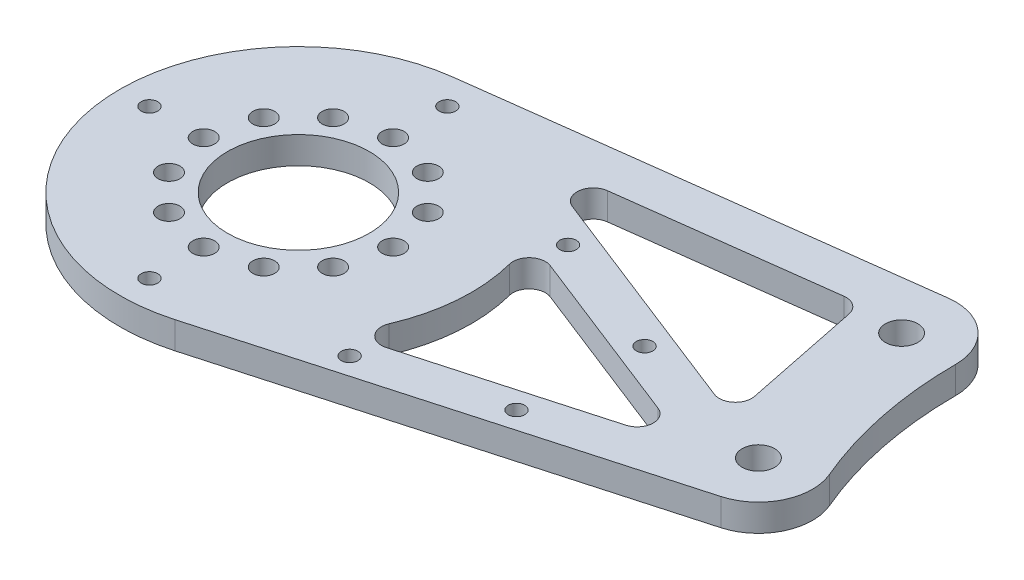
from build123d import *

# Parameters (mm, degrees)
SKETCH_1_R          = 2.025
SKETCH_1_R_2        = 13.1
SKETCH_1_R_3        = 3
EXTRUDE_1_DEPTH     = 5
CUT_EXTRUDE_3_DEPTH = 10
FILLET_2_R          = 3
SKETCH_5_R          = 1.525
CUT_EXTRUDE_4_DEPTH = 20


with BuildPart() as part:
    # 草图1 → 凸台-拉伸1 (new body)
    with BuildSketch(Plane(origin=(0, 0, 0), x_dir=(1, 0, 0), z_dir=(0, 1, 0))):
        with BuildLine():
            Line((76.972140647, 43.13107423), (-4.193547259, 32.732463418))
            ThreePointArc((-4.193547259, 32.732463418), (-32.337515252, -6.579141836), (8.929411765, -31.768940894))
            Line((8.929411765, -31.768940894), (87.705882353, -9.626951786))
            ThreePointArc((87.705882353, -9.626951786), (94.014523475, -4.328783491), (94.205048973, 3.907310252))
            ThreePointArc((94.205048973, 3.907310252), (89.748559809, 18.25955029), (88.242912543, 33.212145922))
            ThreePointArc((88.242912543, 33.212145922), (84.849435117, 40.719066694), (76.972140647, 43.13107423))
        make_face()
        with Locations((0, 17.5)):
            Circle(SKETCH_1_R, mode=Mode.SUBTRACT)
        with Locations((8.75, 15.155444566)):
            Circle(SKETCH_1_R, mode=Mode.SUBTRACT)
        with Locations((-8.75, -15.155444566)):
            Circle(SKETCH_1_R, mode=Mode.SUBTRACT)
        with Locations((0, -17.5)):
            Circle(SKETCH_1_R, mode=Mode.SUBTRACT)
        with Locations((-15.155444566, -8.75)):
            Circle(SKETCH_1_R, mode=Mode.SUBTRACT)
        with Locations((8.75, -15.155444566)):
            Circle(SKETCH_1_R, mode=Mode.SUBTRACT)
        with Locations((15.155444566, -8.75)):
            Circle(SKETCH_1_R, mode=Mode.SUBTRACT)
        with Locations((-17.5, 0)):
            Circle(SKETCH_1_R, mode=Mode.SUBTRACT)
        Circle(SKETCH_1_R_2, mode=Mode.SUBTRACT)
        with Locations((-15.155444566, 8.75)):
            Circle(SKETCH_1_R, mode=Mode.SUBTRACT)
        with Locations((17.5, 0)):
            Circle(SKETCH_1_R, mode=Mode.SUBTRACT)
        with Locations((15.155444566, 8.75)):
            Circle(SKETCH_1_R, mode=Mode.SUBTRACT)
        with Locations((-8.75, 15.155444566)):
            Circle(SKETCH_1_R, mode=Mode.SUBTRACT)
        with Locations((85, 0)):
            Circle(SKETCH_1_R_3, mode=Mode.SUBTRACT)
        with Locations((78.242912543, 33.212145922)):
            Circle(SKETCH_1_R_3, mode=Mode.SUBTRACT)
    extrude(amount=EXTRUDE_1_DEPTH)

    # 草图4 → 切除-拉伸3 (cut)
    with BuildSketch(Plane.XZ):
        with BuildLine():
            Line((76.108728609, 4.576602785), (25.994527014, 18.662383699))
            ThreePointArc((25.994527014, 18.662383699), (30.461655113, 9.802426627), (32, 0))
            ThreePointArc((32, 0), (31.185942012, -7.171960739), (28.785186198, -13.979021981))
            Line((28.785186198, -13.979021981), (76.108728609, 4.576602785))
        make_face()
        Polygon((69.770383541, -34.143027562), (16.636114037, -27.335685646), (75.881597407, -4.105451761), align=None)
    extrude(amount=-CUT_EXTRUDE_3_DEPTH, mode=Mode.SUBTRACT)

    # 圆角2
    fillet_2_edges = [part.edges().sort_by_distance(p)[0] for p in [
        (69.770383541, 2.5, -34.143027562),
        (16.636114037, 2.5, -27.335685646),
        (75.881597407, 2.5, -4.105451761),
        (28.785186198, 2.5, -13.979021981),
        (25.994527014, 2.5, 18.662383699),
        (76.108728609, 2.5, 4.576602785),
    ]]
    fillet(fillet_2_edges, radius=FILLET_2_R)

    # 草图5 → 切除-拉伸4 (cut)
    with BuildSketch(Plane(origin=(0, 5, 0), x_dir=(1, 0, 0), z_dir=(0, 1, 0))):
        with Locations((-27.522163408, 0)):
            Circle(SKETCH_5_R)
        with Locations((0, 27.522163408)):
            Circle(SKETCH_5_R)
        with Locations((0, -27.522163408)):
            Circle(SKETCH_5_R)
        with Locations((30.901702525, -21.438107622)):
            Circle(SKETCH_5_R)
        with Locations((54.969081991, -14.673401739)):
            Circle(SKETCH_5_R)
        with Locations((33.321534862, 16.496811603)):
            Circle(SKETCH_5_R)
        with Locations((56.596303964, 7.370743267)):
            Circle(SKETCH_5_R)
    extrude(amount=-CUT_EXTRUDE_4_DEPTH, mode=Mode.SUBTRACT)


solid = part.part
